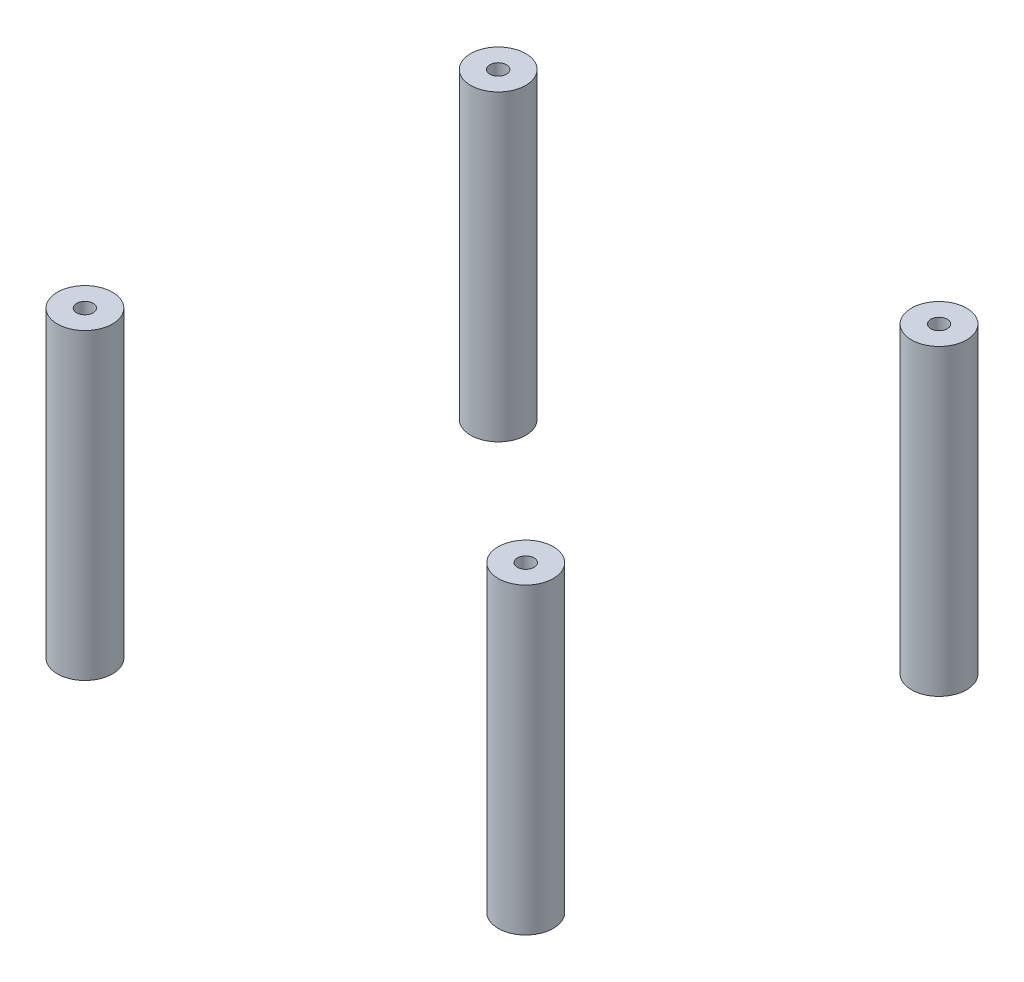
from build123d import *

# Parameters (mm, degrees)
SKETCH1_R             = 5
SKETCH1_R_2           = 1.5
BOSS_EXTRUDE1_DEPTH   = 55
BOSS_EXTRUDE1_2_DEPTH = 55
BOSS_EXTRUDE1_3_DEPTH = 55
BOSS_EXTRUDE1_4_DEPTH = 55


with BuildPart() as part:
    # Sketch1 → Boss-Extrude1 (new body)
    with BuildSketch(Plane(origin=(0, 0, 0), x_dir=(1, 0, 0), z_dir=(0, 1, 0))):
        with Locations((-40, 37.5)):
            Circle(SKETCH1_R)
        with Locations((-40, 37.5)):
            Circle(SKETCH1_R_2, mode=Mode.SUBTRACT)
    extrude(amount=BOSS_EXTRUDE1_DEPTH)


with BuildPart() as body_2:
    # Sketch1 → Boss-Extrude1 2 (new body)
    with BuildSketch(Plane(origin=(0, 0, 0), x_dir=(1, 0, 0), z_dir=(0, 1, 0))):
        with Locations((40, 37.5)):
            Circle(SKETCH1_R)
        with Locations((40, 37.5)):
            Circle(SKETCH1_R_2, mode=Mode.SUBTRACT)
    extrude(amount=BOSS_EXTRUDE1_2_DEPTH)


with BuildPart() as body_3:
    # Sketch1 → Boss-Extrude1 3 (new body)
    with BuildSketch(Plane(origin=(0, 0, 0), x_dir=(1, 0, 0), z_dir=(0, 1, 0))):
        with Locations((40, -37.5)):
            Circle(SKETCH1_R)
        with Locations((40, -37.5)):
            Circle(SKETCH1_R_2, mode=Mode.SUBTRACT)
    extrude(amount=BOSS_EXTRUDE1_3_DEPTH)


with BuildPart() as body_4:
    # Sketch1 → Boss-Extrude1 4 (new body)
    with BuildSketch(Plane(origin=(0, 0, 0), x_dir=(1, 0, 0), z_dir=(0, 1, 0))):
        with Locations((-40, -37.5)):
            Circle(SKETCH1_R)
        with Locations((-40, -37.5)):
            Circle(SKETCH1_R_2, mode=Mode.SUBTRACT)
    extrude(amount=BOSS_EXTRUDE1_4_DEPTH)


solid = Compound([part.part, body_2.part, body_3.part, body_4.part])
